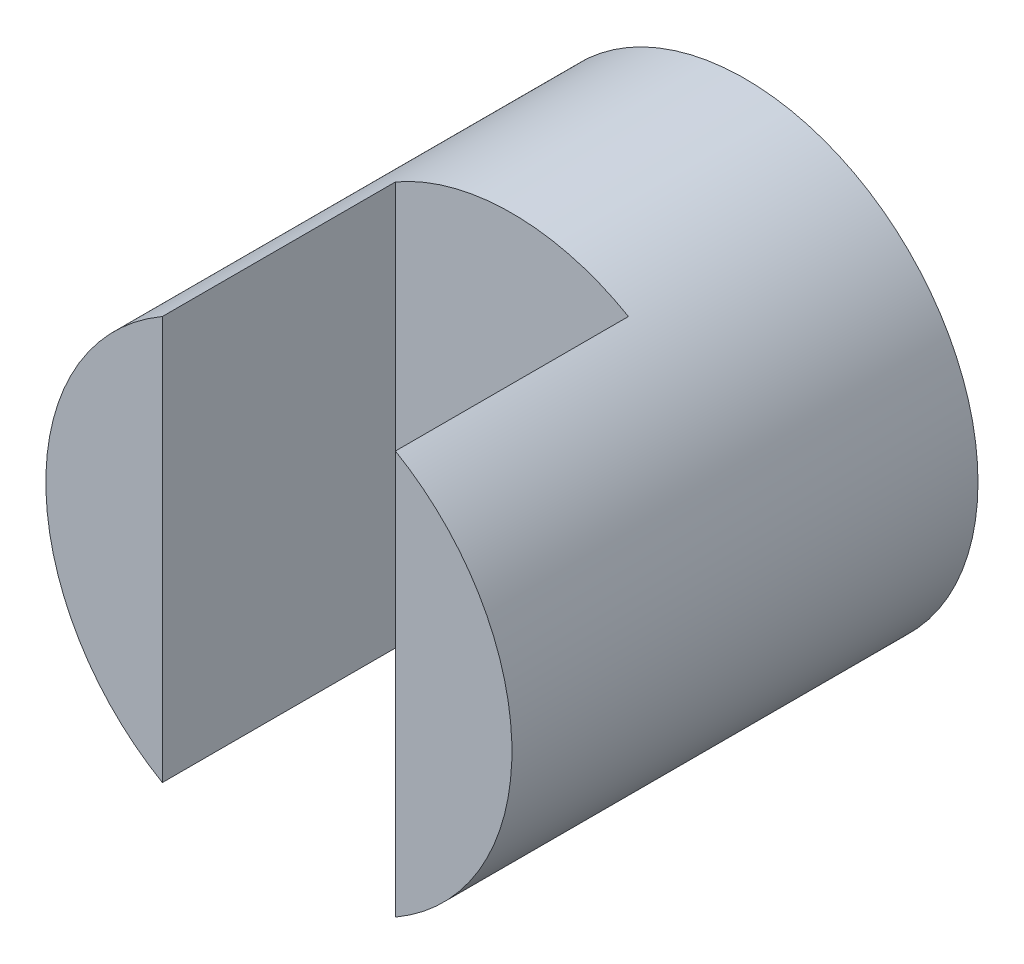
from build123d import *

# Parameters (mm, degrees)
SKETCH1_R           = 2
BOSS_EXTRUDE1_DEPTH = 4
SKETCH2_W           = 2
SKETCH2_H           = 4
CUT_EXTRUDE1_DEPTH  = 2


with BuildPart() as part:
    # Sketch1 → Boss-Extrude1 (new body)
    with BuildSketch(Plane.XY):
        Circle(SKETCH1_R)
    extrude(amount=BOSS_EXTRUDE1_DEPTH)

    # Sketch2 → Cut-Extrude1 (cut, symmetric)
    with BuildSketch(Plane(origin=(0, 0, 0), x_dir=(1, 0, 0), z_dir=(0, 1, 0))):
        with Locations((0, -4)):
            Rectangle(SKETCH2_W, SKETCH2_H)
    extrude(amount=CUT_EXTRUDE1_DEPTH, both=True, mode=Mode.SUBTRACT)


solid = part.part
